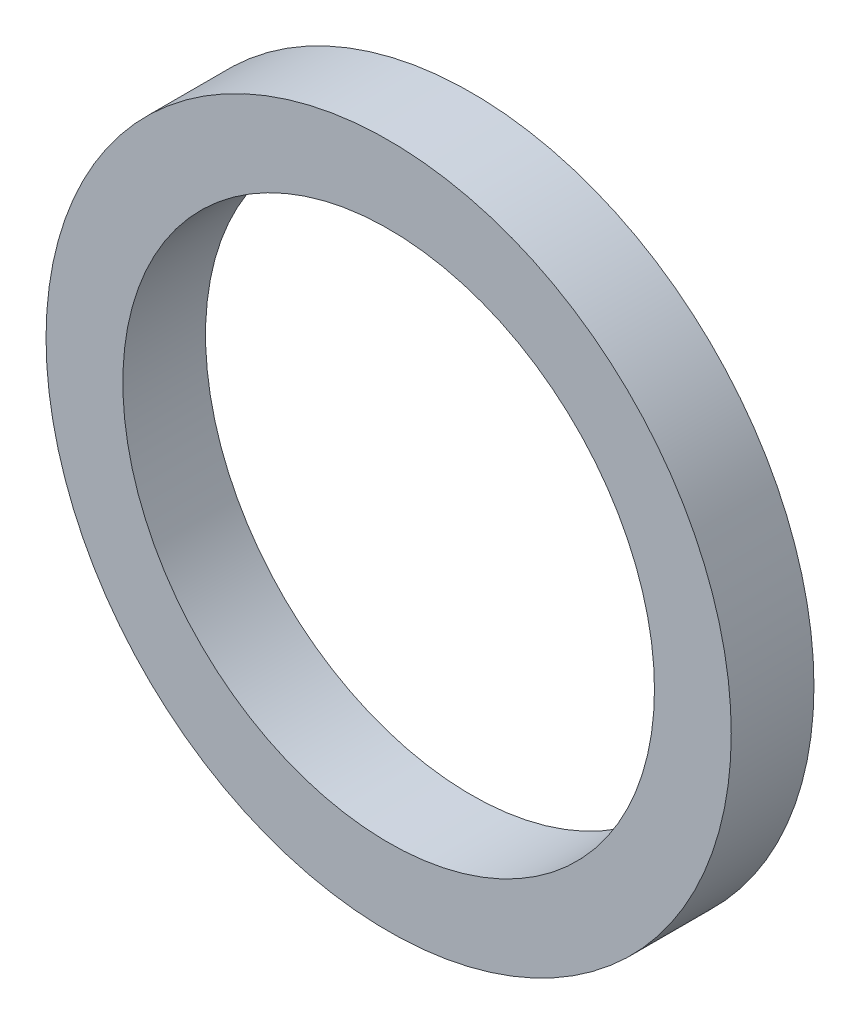
from build123d import *

# Parameters (mm, degrees)
SKETCH1_R           = 29
SKETCH1_R_2         = 22.5
BOSS_EXTRUDE1_DEPTH = 3.5


with BuildPart() as part:
    # Sketch1 → Boss-Extrude1 (new body, symmetric)
    with BuildSketch(Plane.XY):
        Circle(SKETCH1_R)
        Circle(SKETCH1_R_2, mode=Mode.SUBTRACT)
    extrude(amount=BOSS_EXTRUDE1_DEPTH, both=True)


solid = part.part
